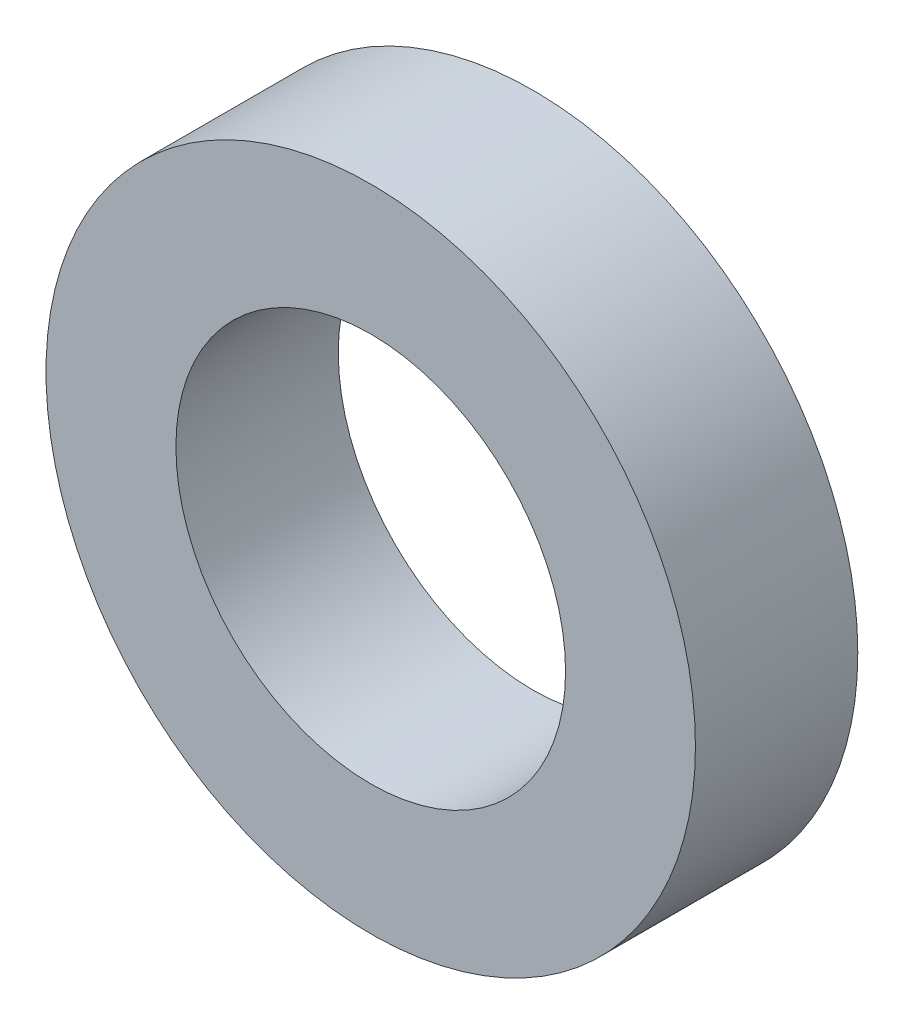
from build123d import *

# Parameters (mm, degrees)
SKETCH_1_R      = 5
SKETCH_1_R_2    = 3
EXTRUDE_1_DEPTH = 2.5


with BuildPart() as part:
    # ｽｹｯﾁ1 → ﾎﾞｽ - 押し出し1 (new body)
    with BuildSketch(Plane.XY):
        Circle(SKETCH_1_R)
        Circle(SKETCH_1_R_2, mode=Mode.SUBTRACT)
    extrude(amount=EXTRUDE_1_DEPTH)


solid = part.part
